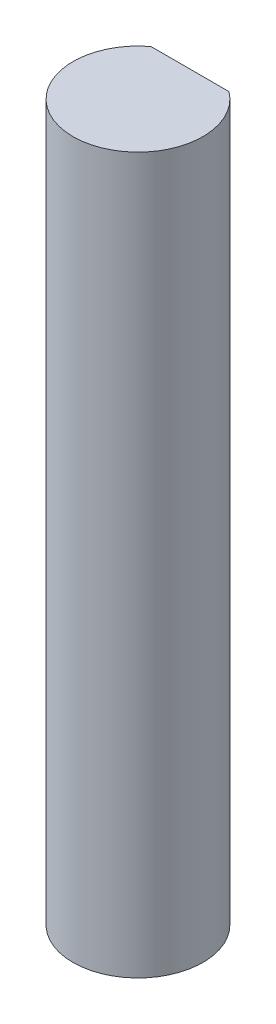
from build123d import *

# Parameters (mm, degrees)
BOSS_EXTRUDE1_DEPTH = 34.925


with BuildPart() as part:
    # Sketch1 → Boss-Extrude1 (new body)
    with BuildSketch(Plane(origin=(0, 0, 0), x_dir=(1, 0, 0), z_dir=(0, 1, 0))):
        with BuildLine():
            Line((-1.905, 2.54), (1.905, 2.54))
            ThreePointArc((1.905, 2.54), (0, -3.175), (-1.905, 2.54))
        make_face()
    extrude(amount=BOSS_EXTRUDE1_DEPTH)


solid = part.part
